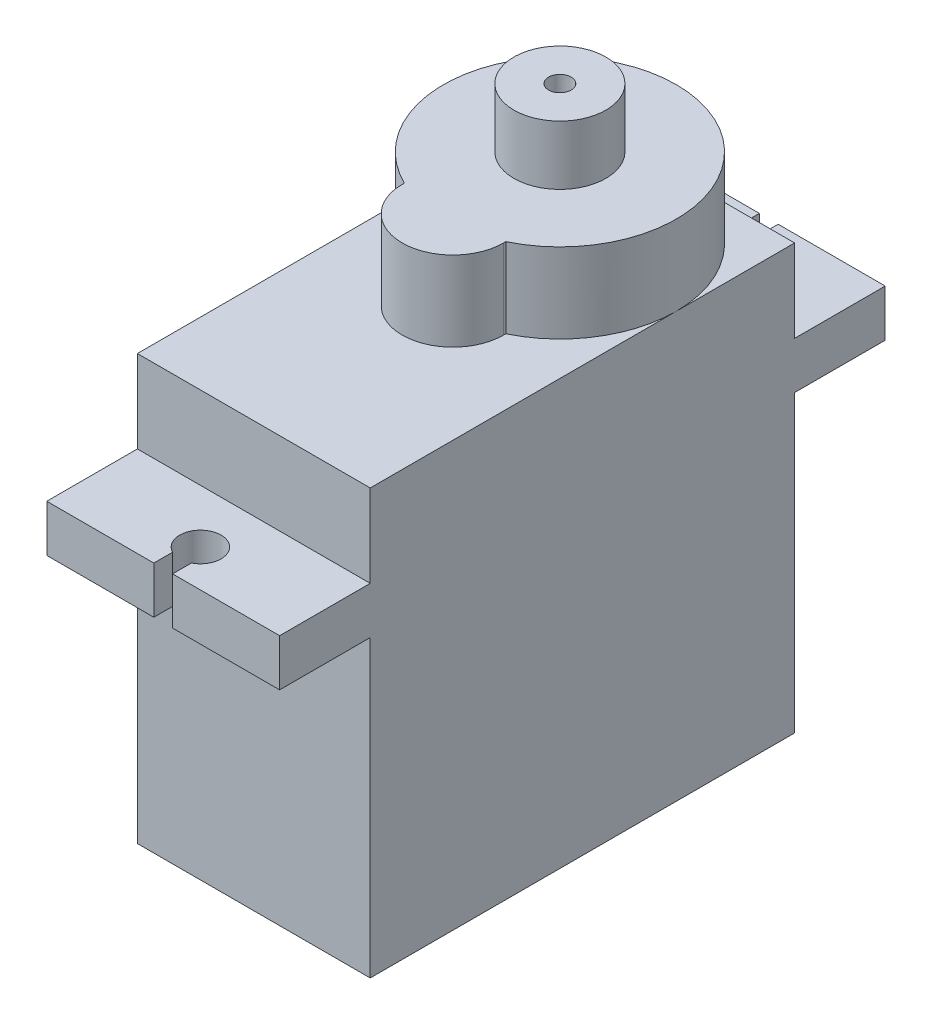
from build123d import *

# Parameters (mm, degrees)
IZIM1_W                     = 12.4
IZIM1_H                     = 22.6
Y_KSEKLIK_EKSTR_ZYON1_DEPTH = 22.6
Y_KSEKLIK_EKSTR_ZYON2_DEPTH = 2.5
IZIM3_W                     = 3.6
IZIM3_H                     = 3
Y_KSEKLIK_EKSTR_ZYON3_DEPTH = 1.2
IZIM4_R                     = 6.2
Y_KSEKLIK_EKSTR_ZYON4_DEPTH = 4.25
IZIM5_R                     = 2.45
IZIM5_R_2                   = 0.6
Y_KSEKLIK_EKSTR_ZYON6_DEPTH = 3.15
IZIM6_W                     = 0.1
IZIM6_H                     = 1.2
KES_EKSTR_ZYON1_DEPTH       = 3
RADYUS1_R                   = 0.5


with BuildPart() as part:
    # Çizim1 → Yükseklik-Ekstrüzyon1 (new body)
    with BuildSketch(Plane(origin=(0, 0, 0), x_dir=(1, 0, 0), z_dir=(0, 1, 0))):
        Rectangle(IZIM1_W, IZIM1_H)
    extrude(amount=Y_KSEKLIK_EKSTR_ZYON1_DEPTH)

    # Çizim2 → Yükseklik-Ekstrüzyon2 (add)
    with BuildSketch(Plane(origin=(0, 18.2, 0), x_dir=(1, 0, 0), z_dir=(0, 1, 0))):
        with BuildLine():
            Line((-6.2, 16.125), (-6.2, -16.125))
            Line((-6.2, -16.125), (-0.5, -16.125))
            Line((-0.5, -16.125), (-0.5, -15.125))
            ThreePointArc((-0.5, -15.125), (-0.574456265, -13.207120951), (1.1, -14.145204103))
            ThreePointArc((1.1, -14.145204103), (0.938083152, -14.719660368), (0.5, -15.125))
            Line((0.5, -15.125), (0.5, -16.125))
            Line((0.5, -16.125), (6.2, -16.125))
            Line((6.2, -16.125), (6.2, 16.125))
            Line((6.2, 16.125), (0.5, 16.125))
            Line((0.5, 16.125), (0.5, 15.125))
            ThreePointArc((0.5, 15.125), (0.938083152, 14.719660368), (1.1, 14.145204103))
            ThreePointArc((1.1, 14.145204103), (-0.574456265, 13.207120951), (-0.5, 15.125))
            Line((-0.5, 15.125), (-0.5, 16.125))
            Line((-0.5, 16.125), (-6.2, 16.125))
        make_face()
    extrude(amount=-Y_KSEKLIK_EKSTR_ZYON2_DEPTH)

    # Çizim3 → Yükseklik-Ekstrüzyon3 (add)
    with BuildSketch(Plane(origin=(0, 4.8, 0), x_dir=(-1, 0, 0), z_dir=(0, -1, 0))):
        with Locations((0, 12.8)):
            Rectangle(IZIM3_W, IZIM3_H)
    extrude(amount=Y_KSEKLIK_EKSTR_ZYON3_DEPTH)

    # Çizim4 → Yükseklik-Ekstrüzyon4 (add)
    with BuildSketch(Plane(origin=(0, 22.6, 0), x_dir=(1, 0, 0), z_dir=(0, 1, 0))):
        with Locations((0, 5)):
            Circle(IZIM4_R)
        with BuildLine():
            Line((-2.7, -0.581218505), (-2.7, -0.7))
            ThreePointArc((-2.7, -0.7), (0, -3.4), (2.7, -0.7))
            Line((2.7, -0.7), (2.7, -0.581218505))
            ThreePointArc((2.7, -0.581218505), (0, -1.2), (-2.7, -0.581218505))
        make_face()
    extrude(amount=Y_KSEKLIK_EKSTR_ZYON4_DEPTH)

    # Çizim5 → Yükseklik-Ekstrüzyon6 (add)
    with BuildSketch(Plane(origin=(0, 26.85, 0), x_dir=(1, 0, 0), z_dir=(0, 1, 0))):
        with Locations((0, 5)):
            Circle(IZIM5_R)
        with Locations((0, 5)):
            Circle(IZIM5_R_2, mode=Mode.SUBTRACT)
    extrude(amount=Y_KSEKLIK_EKSTR_ZYON6_DEPTH)

    # Çizim6 → Kes-Ekstrüzyon1 (cut)
    with BuildSketch(Plane(origin=(0, 0, -14.3), x_dir=(-1, 0, 0), z_dir=(0, 0, -1))):
        with Locations((-0.616666667, 4.2)):
            Rectangle(IZIM6_W, IZIM6_H)
        with Locations((0.616666667, 4.2)):
            Rectangle(IZIM6_W, IZIM6_H)
    extrude(amount=-KES_EKSTR_ZYON1_DEPTH, mode=Mode.SUBTRACT)

    # Radyus1
    radyus1_edges = [part.edges().sort_by_distance(p)[0] for p in [
        (0.566666667, 3.6, -12.8),
        (0.566666667, 4.8, -12.8),
        (0.666666667, 4.8, -12.8),
        (0.666666667, 3.6, -12.8),
        (-0.666666667, 3.6, -12.8),
        (-0.666666667, 4.8, -12.8),
        (-0.566666667, 4.8, -12.8),
        (-0.566666667, 3.6, -12.8),
        (1.8, 4.8, -12.8),
        (-1.8, 4.8, -12.8),
        (1.8, 3.6, -12.8),
        (-1.8, 3.6, -12.8),
    ]]
    fillet(radyus1_edges, radius=RADYUS1_R)


solid = part.part
